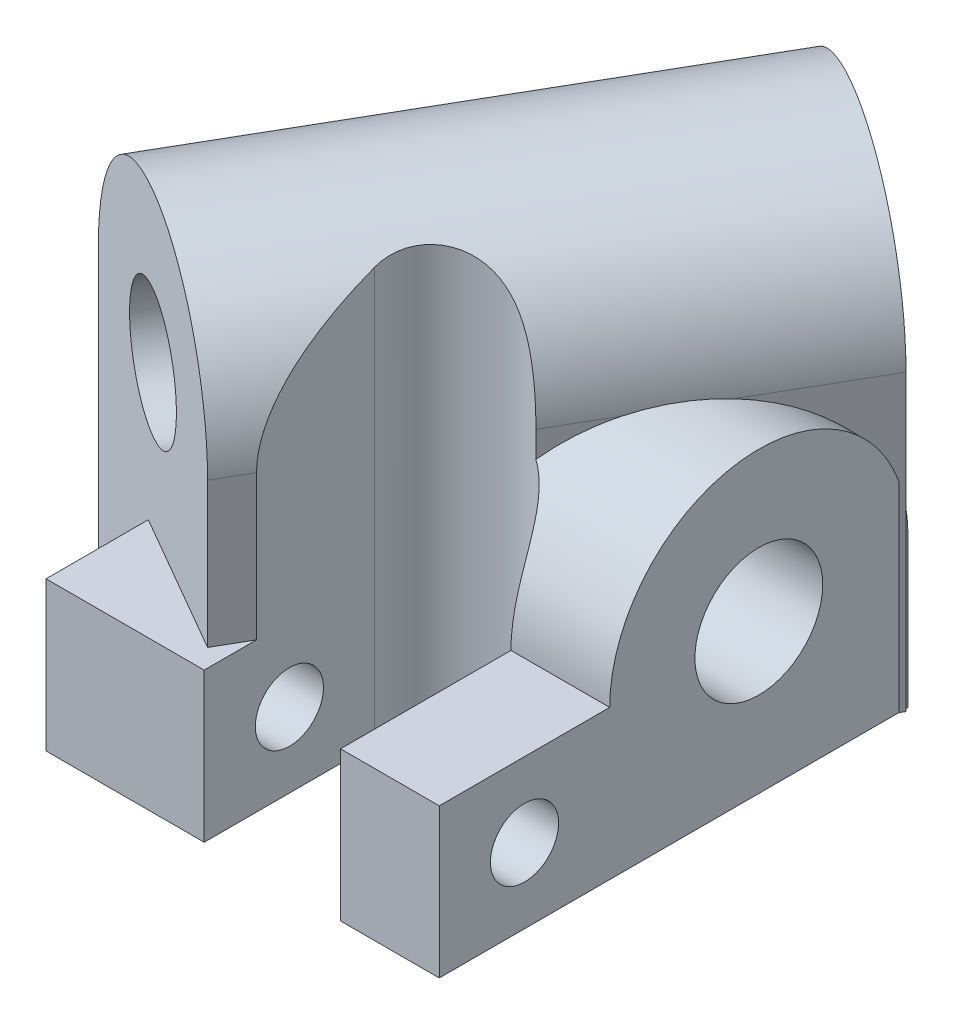
from build123d import *

# Parameters (mm, degrees)
SKETCH1_R           = 3.75
BOSS_EXTRUDE1_DEPTH = 30
SKETCH2_R           = 3.75
BOSS_EXTRUDE2_DEPTH = 30
CUT_EXTRUDE1_DEPTH  = 27.0000001
SKETCH4_W           = 5.792740578
SKETCH4_H           = 10
BOSS_EXTRUDE3_DEPTH = 8.75
BOSS_EXTRUDE4_DEPTH = 8.75
SKETCH5_R           = 2
CUT_EXTRUDE2_DEPTH  = 31.0000001
SKETCH7_R           = 3.75
CUT_EXTRUDE3_DEPTH  = 31.155444666
SKETCH8_R           = 3.75
CUT_EXTRUDE4_DEPTH  = 38.57772242


with BuildPart() as part:
    # Sketch1 → Boss-Extrude1 (new body)
    with BuildSketch(Plane(origin=(0, 0, 0), x_dir=(0, 0, -1), z_dir=(1, 0, 0))):
        with BuildLine():
            Line((-8.75, 0), (8.75, 0))
            Line((8.75, 0), (8.75, 8.75))
            ThreePointArc((8.75, 8.75), (0, 17.5), (-8.75, 8.75))
            Line((-8.75, 8.75), (-8.75, 0))
        make_face()
        with Locations((0, 8.75)):
            Circle(SKETCH1_R, mode=Mode.SUBTRACT)
    extrude(amount=BOSS_EXTRUDE1_DEPTH)

    # Sketch2 → Boss-Extrude2 (add)
    with BuildSketch(Plane(origin=(-3.788861142, 0, 6.5625), x_dir=(-0.866025404, 0, -0.5), z_dir=(0.5, 0, -0.866025404))):
        with BuildLine():
            Line((-4.375, 0), (-4.375, 17.25))
            ThreePointArc((-4.375, 17.25), (-13.125, 26), (-21.875, 17.25))
            Line((-21.875, 17.25), (-21.875, 0))
            Line((-21.875, 0), (-4.375, 0))
        make_face()
        with Locations((-13.125, 17.25)):
            Circle(SKETCH2_R, mode=Mode.SUBTRACT)
    extrude(amount=BOSS_EXTRUDE2_DEPTH)

    # Sketch3 → Cut-Extrude1 (cut, through all)
    with BuildSketch(Plane.XZ):
        with BuildLine():
            Line((24.207259422, 8.75), (24.207259422, 15.67820323))
            Line((24.207259422, 15.67820323), (16.207259422, 15.67820323))
            Line((16.207259422, 15.67820323), (16.207259422, 8.75))
            ThreePointArc((16.207259422, 8.75), (20.207259422, 4.75), (24.207259422, 8.75))
        make_face()
    extrude(amount=-CUT_EXTRUDE1_DEPTH, mode=Mode.SUBTRACT)

    # Sketch4 → Boss-Extrude3 (add)
    with BuildSketch(Plane.XZ):
        with Locations((27.103629711, 13.75)):
            Rectangle(SKETCH4_W, SKETCH4_H)
    extrude(amount=-BOSS_EXTRUDE3_DEPTH)

    # Sketch6 → Boss-Extrude4 (add)
    with BuildSketch(Plane.XZ):
        Polygon((16.207259422, 15.67820323), (16.207259422, 18.75), (6.92820323, 18.75), (6.92820323, 12.75), align=None)
    extrude(amount=-BOSS_EXTRUDE4_DEPTH)

    # Sketch5 → Cut-Extrude2 (cut, through all)
    with BuildSketch(Plane(origin=(30, 0, 0), x_dir=(0, 0, -1), z_dir=(1, 0, 0))):
        with Locations(Location((-13.75, 4.375, 0), (0, 0, 60))):  # turned: the seam where the file's is
            Circle(SKETCH5_R)
    extrude(amount=-CUT_EXTRUDE2_DEPTH, mode=Mode.SUBTRACT)

    # Sketch7 → Cut-Extrude3 (cut, through all)
    with BuildSketch(Plane.ZY):
        with Locations(Location((0, 8.75, 0), (0, 0, 180))):  # turned: the seam where the file's is
            Circle(SKETCH7_R)
    extrude(amount=-CUT_EXTRUDE3_DEPTH, mode=Mode.SUBTRACT)

    # Sketch8 → Cut-Extrude4 (cut, through all)
    with BuildSketch(Plane(origin=(-3.788861142, 0, 6.5625), x_dir=(0.866025404, 0, 0.5), z_dir=(-0.5, 0, 0.866025404))):
        with Locations(Location((13.125, 17.25, 0), (0, 0, 180))):  # turned: the seam where the file's is
            Circle(SKETCH8_R)
    extrude(amount=-CUT_EXTRUDE4_DEPTH, mode=Mode.SUBTRACT)


solid = part.part
